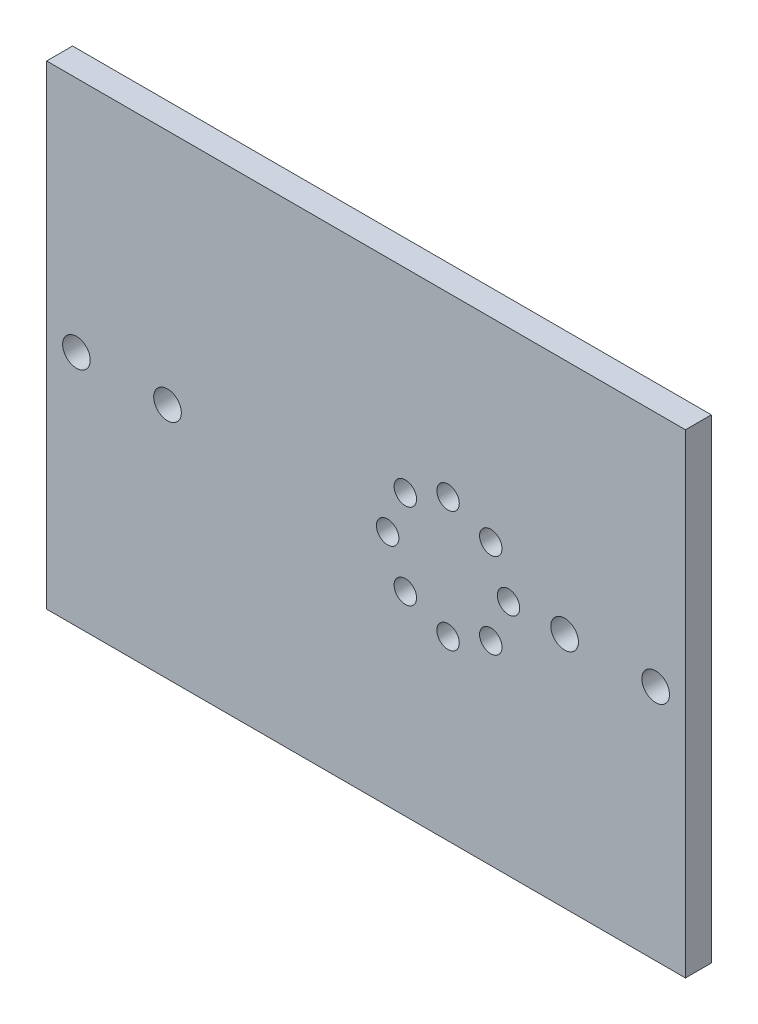
from build123d import *

# Parameters (mm, degrees)
SKETCH_1_W          = 74
SKETCH_1_H          = 55
EXTRUDE_1_DEPTH     = 3
SKETCH_2_R          = 1.6
CUT_EXTRUDE_1_DEPTH = 47.197943677
SKETCH_2_3_R        = 1.3
CUT_EXTRUDE_2_DEPTH = 47.197943677


with BuildPart() as part:
    # 草圖1 → 填料-伸長1 (new body)
    with BuildSketch(Plane.XY):
        Rectangle(SKETCH_1_W, SKETCH_1_H)
    extrude(amount=EXTRUDE_1_DEPTH)

    # 草圖2 → 除料-伸長1 (cut, through all)
    with BuildSketch(Plane.XY.offset(3)):
        with Locations((-33.55, 0)):
            Circle(SKETCH_2_R)
        with Locations((33.55, 0)):
            Circle(SKETCH_2_R)
        with Locations((-23, 0)):
            Circle(SKETCH_2_R)
        with Locations((23, 0)):
            Circle(SKETCH_2_R)
    extrude(amount=-CUT_EXTRUDE_1_DEPTH, mode=Mode.SUBTRACT)

    # 草圖2<3> → 除料-伸長2 (cut, through all)
    with BuildSketch(Plane.XY.offset(3)):
        with Locations((16.5, 0)):
            Circle(SKETCH_2_3_R)
        with Locations((14.449747468, -4.949747468)):
            Circle(SKETCH_2_3_R)
        with Locations((9.5, -7)):
            Circle(SKETCH_2_3_R)
        with Locations((4.550252532, -4.949747468)):
            Circle(SKETCH_2_3_R)
        with Locations((2.5, 0)):
            Circle(SKETCH_2_3_R)
        with Locations((4.550252532, 4.949747468)):
            Circle(SKETCH_2_3_R)
        with Locations((9.5, 7)):
            Circle(SKETCH_2_3_R)
        with Locations((14.449747468, 4.949747468)):
            Circle(SKETCH_2_3_R)
    extrude(amount=-CUT_EXTRUDE_2_DEPTH, mode=Mode.SUBTRACT)


solid = part.part
